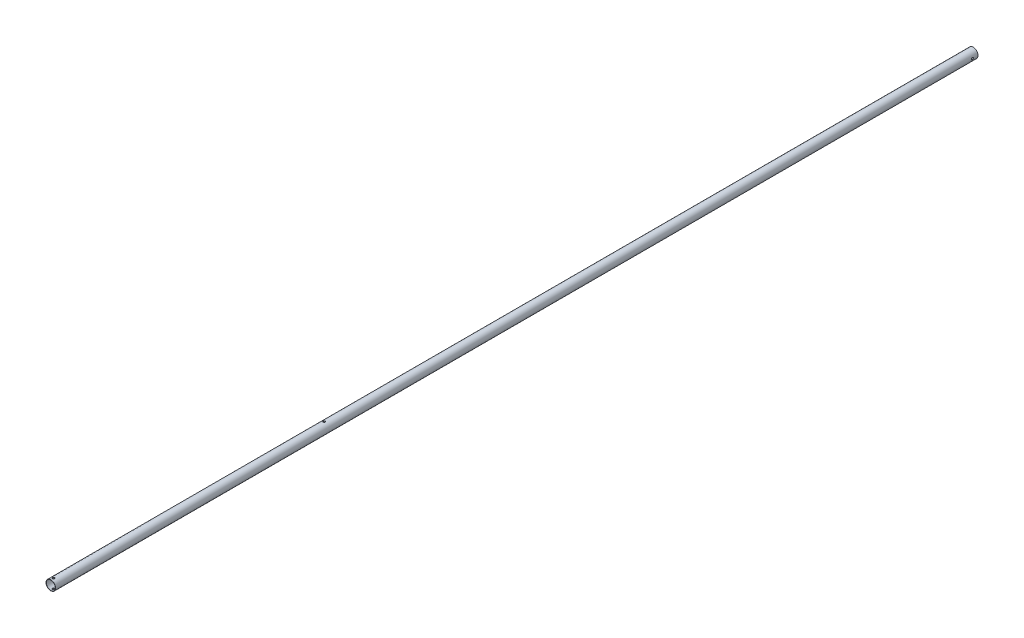
from build123d import *

# Parameters (mm, degrees)
SKETCH1_R               = 12.7
SKETCH1_R_2             = 11.90625
BOSS_EXTRUDE1_DEPTH     = 2443.872227937
SKETCH4_W               = 2.75
SKETCH4_H               = 12.7
SKETCH12_W              = 2.75
SKETCH12_H              = 12.7
SKETCH13_R              = 2.750000003
CUT_EXTRUDE1_DEPTH      = 13.7000001
CUT_EXTRUDE1_DEPTH_BACK = 13.7000001


with BuildPart() as part:
    # Sketch1 → Boss-Extrude1 (new body)
    with BuildSketch(Plane.XY):
        Circle(SKETCH1_R)
        Circle(SKETCH1_R_2, mode=Mode.SUBTRACT)
    extrude(amount=BOSS_EXTRUDE1_DEPTH)

    # Sketch4 → M5 Clearance Hole1 (revolve, cut)
    with BuildSketch(Plane(origin=(0, 0, 2436.622227937), x_dir=(0, 0, -1), z_dir=(1, 0, 0))):
        with Locations((1.375, 6.35)):
            Rectangle(SKETCH4_W, SKETCH4_H)
    m5_clearance_hole1 = revolve(axis=Axis((0, -6.35, 2436.622227937), (0, 1, 0)), mode=Mode.SUBTRACT)

    # Mirror1: M5 Clearance Hole1 across plane
    add(m5_clearance_hole1.mirror(Plane.ZX), mode=Mode.SUBTRACT)

    # Sketch12 → M5 Clearance Hole3 (revolve, cut)
    with BuildSketch(Plane(origin=(0, 0, 15), x_dir=(0, 0, 1), z_dir=(0, 1, 0))):
        with Locations((1.375, 6.35)):
            Rectangle(SKETCH12_W, SKETCH12_H)
    m5_clearance_hole3 = revolve(axis=Axis((-6.35, 0, 15), (1, 0, 0)), mode=Mode.SUBTRACT)

    # Mirror3: M5 Clearance Hole3 across plane
    add(m5_clearance_hole3.mirror(Plane(origin=(0, 0, 0), x_dir=(0, 0, 1), z_dir=(1, 0, 0))), mode=Mode.SUBTRACT)

    # Sketch13 → Cut-Extrude1 (cut, two sides)
    with BuildSketch(Plane(origin=(0, 0, 0), x_dir=(1, 0, 0), z_dir=(0, 1, 0))) as cut_extrude1_sk:
        with Locations((-0.739798723, -1718.754532743)):
            Circle(SKETCH13_R)
    extrude(amount=CUT_EXTRUDE1_DEPTH, mode=Mode.SUBTRACT)
    extrude(cut_extrude1_sk.sketch, amount=-CUT_EXTRUDE1_DEPTH_BACK, mode=Mode.SUBTRACT)


solid = part.part
